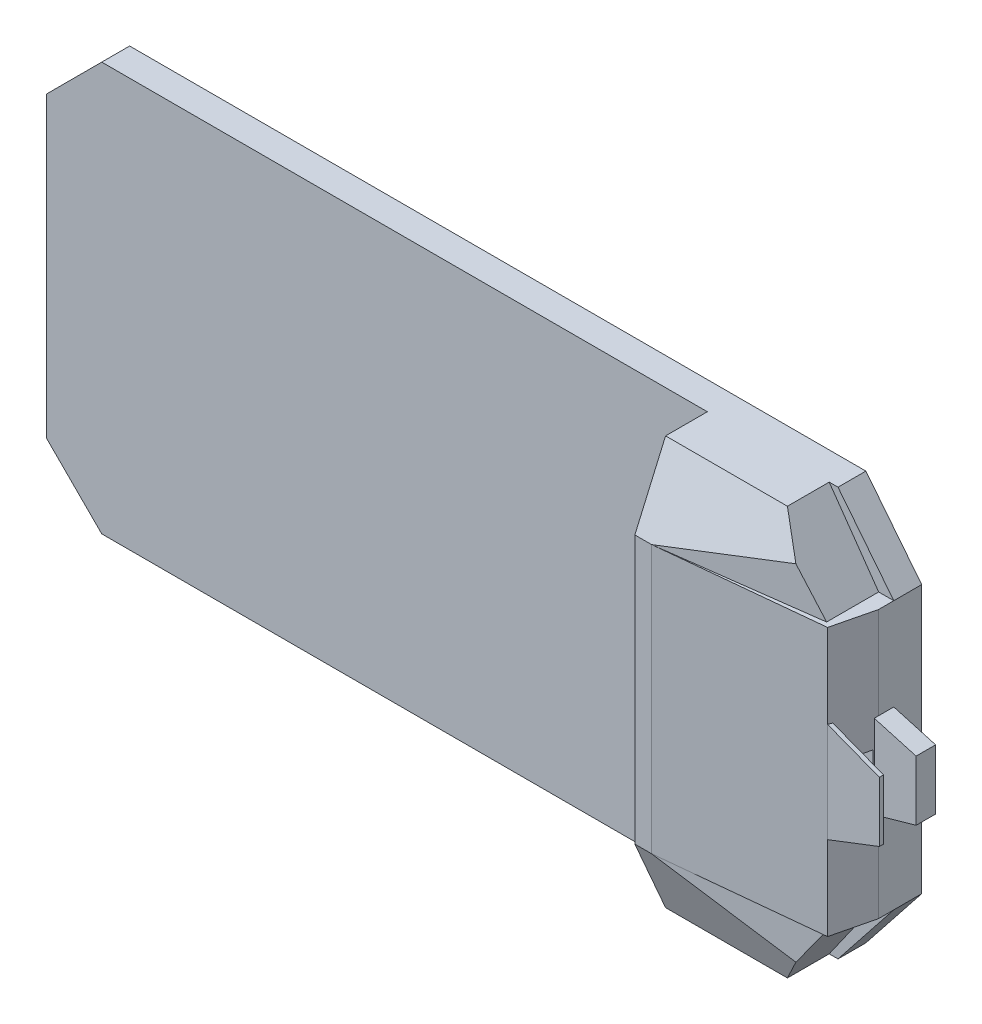
from build123d import *

# Parameters (mm, degrees)
BOSS_EXTRUDE1_DEPTH = 100
BOSS_EXTRUDE2_DEPTH = 30
BOSS_EXTRUDE3_DEPTH = 480
BOSS_EXTRUDE6_DEPTH = 70
BOSS_EXTRUDE7_DEPTH = 15
BOSS_EXTRUDE8_DEPTH = 252.5
BOSS_EXTRUDE9_REACH = 262
SKETCH15_W          = 587.219841395
SKETCH15_H          = 796.289062858
CUT_EXTRUDE1_DEPTH  = 400
SKETCH17_W          = 242.752536278
SKETCH17_H          = 431.304427501
CUT_EXTRUDE2_DEPTH  = 150
SKETCH18_W          = 4260.921249802
SKETCH18_H          = 1605.776736753
CUT_EXTRUDE3_DEPTH  = 1872
SKETCH19_W          = 40
SKETCH19_H          = 100
CUT_EXTRUDE4_DEPTH  = 116.703964


with BuildPart() as part:
    # Sketch1 → Boss-Extrude1 (new body)
    with BuildSketch(Plane.XY):
        Polygon((-1320, -732.5), (-1518.49827194, -534.00172806), (-1518.49827194, 534.00172806), (-1320, 732.5), (1320, 732.5), (1520, 480), (1520, -480), (1320, -732.5), align=None)
    extrude(amount=BOSS_EXTRUDE1_DEPTH)

    # Sketch2 → Boss-Extrude2 (add, symmetric)
    with BuildSketch(Plane.ZY.offset(-881.50172806)):
        Polygon((100, 732.5), (249.797915184, 732.5), (360, 480), (360, -480), (249.797915184, -732.5), (100, -732.5), align=None)
    extrude(amount=BOSS_EXTRUDE2_DEPTH, both=True)

    # Sketch3 → Boss-Extrude3 (add, symmetric)
    with BuildSketch(Plane(origin=(0, 0, 0), x_dir=(1, 0, 0), z_dir=(0, 1, 0))):
        Polygon((1520, -100), (1520, -154.516976287), (1484.328596942, -301.703964205), (911.50172806, -360), (911.50172806, -100), align=None)
    extrude(amount=BOSS_EXTRUDE3_DEPTH, both=True)

    # Sketch10 → Boss-Extrude6 (add)
    with BuildSketch(Plane.XY.offset(100)):
        Polygon((1520, 150), (1670, 107.5), (1670, -107.5), (1520, -150), align=None)
    extrude(amount=BOSS_EXTRUDE6_DEPTH)

    # Sketch11 → Boss-Extrude7 (add)
    with BuildSketch(Plane(origin=(0, 0, 301.703964205), x_dir=(0, -1, 0), z_dir=(0, 0, -1))):
        Polygon((-178.932312311, -1484.328596942), (-107.5, -1670), (107.5, -1670), (159.754145476, -1484.328596942), align=None)
    extrude(amount=BOSS_EXTRUDE7_DEPTH)

    # Sketch14 → Boss-Extrude8 (add)
    with BuildSketch(Plane(origin=(0, 732.5, 0), x_dir=(1, 0, 0), z_dir=(0, 1, 0))):
        Polygon((911.50172806, -100), (911.50172806, -360), (1351.817776589, -301.703964205), (1376.361738529, -100), align=None)
    extrude(amount=-BOSS_EXTRUDE8_DEPTH)

    # Boss-Extrude9: up to this face of the body (flat: up to its plane)
    boss_extrude9_end = Plane(part.part.faces().sort_by_distance((1131.659752325, 606.25, 330.851982103))[0])
    # Sketch16 → Boss-Extrude9 (add, up to the picked face)
    with BuildSketch(Plane.XY.offset(100), mode=Mode.PRIVATE) as boss_extrude9_sk1:
        Polygon((1329.450960679, 674.123815603), (1465.786632852, 480), (1329.450960679, 480), align=None)
    boss_extrude9_tool1 = split(extrude(boss_extrude9_sk1.sketch, amount=BOSS_EXTRUDE9_REACH, mode=Mode.PRIVATE), bisect_by=boss_extrude9_end, keep=Keep.BOTH, mode=Mode.PRIVATE)
    add(boss_extrude9_tool1.solids().sort_by_distance((1374.896185, 544.707939, 100))[0])

    # Sketch15 → Cut-Extrude1 (cut)
    with BuildSketch(Plane(origin=(0, 208.782250156, 478.371332562), x_dir=(1, 0, 0), z_dir=(0, 0.400006251, 0.916512411))):
        with Locations((1205.111648758, 435.889549234)):
            Rectangle(SKETCH15_W, SKETCH15_H)
    extrude(amount=CUT_EXTRUDE1_DEPTH, mode=Mode.SUBTRACT)

    # Sketch17 → Cut-Extrude2 (cut)
    with BuildSketch(Plane(origin=(1207.369633426, 847.951344984, 0), x_dir=(0, 0, -1), z_dir=(0.818341703, 0.574731987, 0))):
        with Locations((-221.376268139, -212.999290638)):
            Rectangle(SKETCH17_W, SKETCH17_H)
    extrude(amount=CUT_EXTRUDE2_DEPTH, mode=Mode.SUBTRACT)

    # Sketch18 → Cut-Extrude3 (cut)
    with BuildSketch(Plane(origin=(0, 0, 0), x_dir=(1, 0, 0), z_dir=(0, 1, 0))):
        with Locations((45.70135603, -435.455529715)):
            Rectangle(SKETCH18_W, SKETCH18_H)
    extrude(amount=-CUT_EXTRUDE3_DEPTH, mode=Mode.SUBTRACT)

    # Mirror1: part across plane


with BuildPart() as part_1:
    add(part.part)
    add(part.part.mirror(Plane.ZX))

    # Sketch19 → Cut-Extrude4 (cut)
    with BuildSketch(Plane.XY.offset(170)):
        with Locations((1500, 0)):
            Rectangle(SKETCH19_W, SKETCH19_H)
    extrude(amount=CUT_EXTRUDE4_DEPTH, mode=Mode.SUBTRACT)


solid = part_1.part
